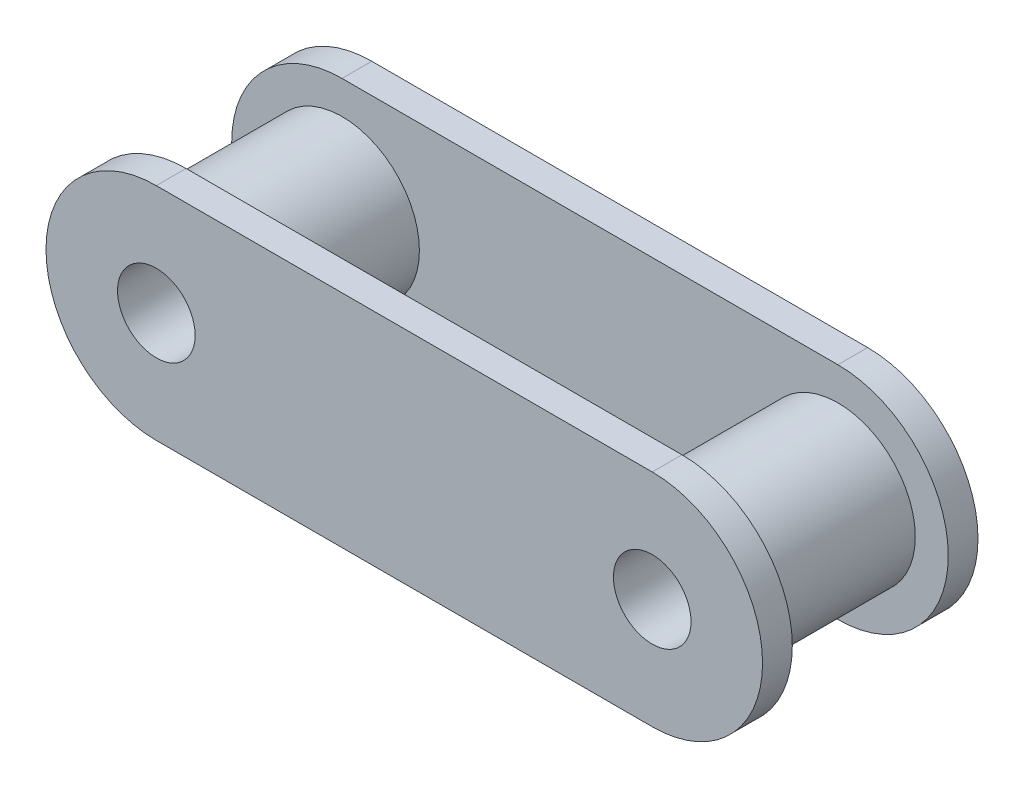
from build123d import *

# Parameters (mm, degrees)
SKETCH1_R           = 1.98755
BOSS_EXTRUDE1_DEPTH = 1.524
SKETCH3_R           = 3.9624
SKETCH3_R_2         = 1.98755
BOSS_EXTRUDE2_DEPTH = 3.99415


with BuildPart() as part:
    # Sketch1 → Boss-Extrude1 (new body)
    with BuildSketch(Plane.XY):
        with BuildLine():
            Line((-12.7, 5.6515), (12.7, 5.6515))
            ThreePointArc((12.7, 5.6515), (18.3515, 0), (12.7, -5.6515))
            Line((12.7, -5.6515), (-12.7, -5.6515))
            ThreePointArc((-12.7, -5.6515), (-18.3515, 0), (-12.7, 5.6515))
        make_face()
        with Locations((-12.7, 0)):
            Circle(SKETCH1_R, mode=Mode.SUBTRACT)
        with Locations((12.7, 0)):
            Circle(SKETCH1_R, mode=Mode.SUBTRACT)
    boss_extrude1 = extrude(amount=BOSS_EXTRUDE1_DEPTH)

    # Sketch3 → Boss-Extrude2 (add)
    with BuildSketch(Plane(origin=(0, 0, 0), x_dir=(-1, 0, 0), z_dir=(0, 0, -1))):
        with Locations((-12.7, 0)):
            Circle(SKETCH3_R)
        with Locations((-12.7, 0)):
            Circle(SKETCH3_R_2, mode=Mode.SUBTRACT)
        with Locations((12.7, 0)):
            Circle(SKETCH3_R)
        with Locations((12.7, 0)):
            Circle(SKETCH3_R_2, mode=Mode.SUBTRACT)
    boss_extrude2 = extrude(amount=BOSS_EXTRUDE2_DEPTH)

    # Mirror4: Boss-Extrude1, Boss-Extrude2 across plane
    add(boss_extrude1.mirror(Plane.XY.offset(-3.99415)))
    add(boss_extrude2.mirror(Plane.XY.offset(-3.99415)))


solid = part.part
